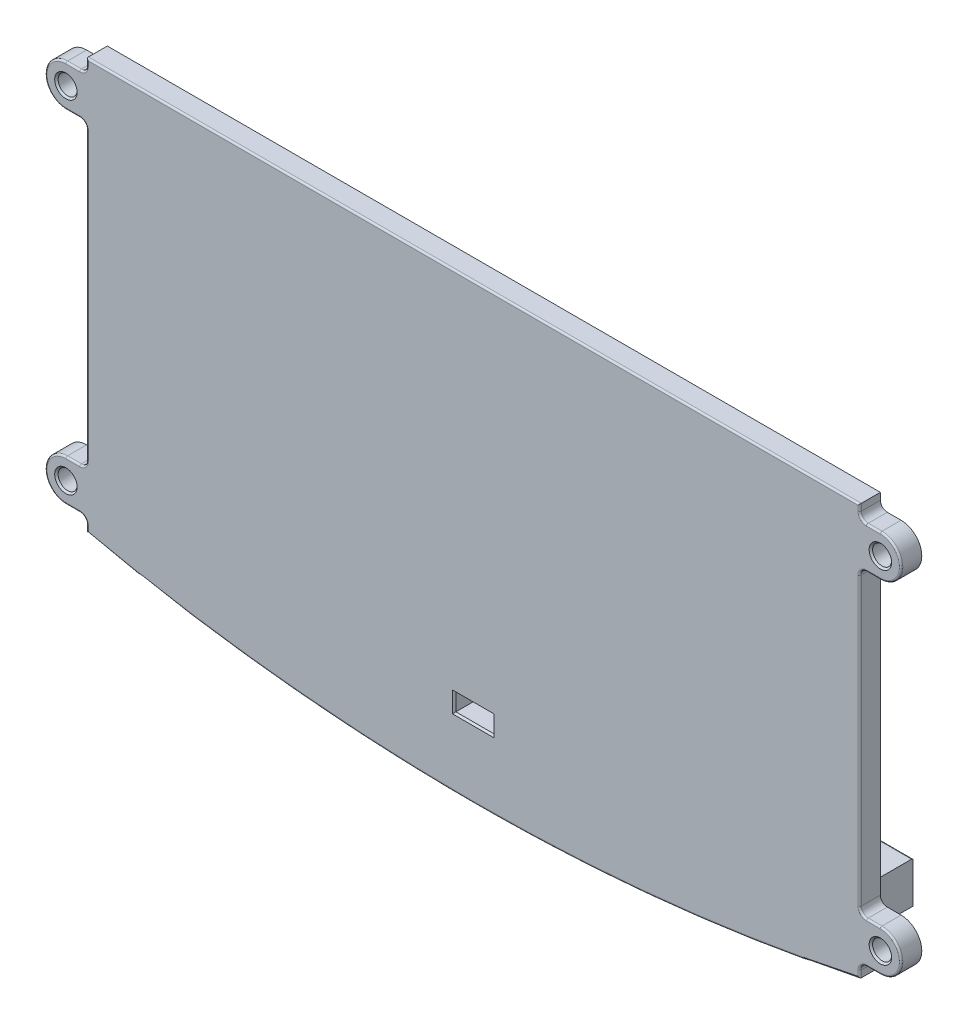
from build123d import *

# Parameters (mm, degrees)
SKETCH1_R           = 1.375
BOSS_EXTRUDE1_DEPTH = 3
SKETCH2_W           = 109
SKETCH2_H           = 3
CUT_EXTRUDE1_DEPTH  = 1.5
CHAMFER1_SIZE       = 0.25
FILLET1_R           = 0.25
SKETCH3_W           = 105.5
SKETCH3_H           = 6
BOSS_EXTRUDE2_DEPTH = 8
SKETCH4_R           = 1.75
CUT_EXTRUDE2_DEPTH  = 58.54
CUT_EXTRUDE3_DEPTH  = 2.5
SKETCH7_W           = 2
SKETCH7_H           = 15.54
SKETCH7_H_2         = 29.75
BOSS_EXTRUDE3_DEPTH = 2.5
CHAMFER2_SIZE       = 0.25
FILLET3_R           = 0.25


with BuildPart() as part:
    # Sketch1 → Boss-Extrude1 (new body)
    with BuildSketch(Plane.XY):
        with BuildLine():
            Line((-56, 3), (56, 3))
            Line((56, 3), (56, 2))
            ThreePointArc((56, 2), (56.292893219, 1.292893219), (57, 1))
            Line((57, 1), (59, 1))
            ThreePointArc((59, 1), (62, -2), (59, -5))
            Line((59, -5), (57, -5))
            ThreePointArc((57, -5), (56.292893219, -5.292893219), (56, -6))
            Line((56, -6), (56, -47.54))
            ThreePointArc((56, -47.54), (56.292893219, -48.247106781), (57, -48.54))
            Line((57, -48.54), (59, -48.54))
            ThreePointArc((59, -48.54), (62, -51.54), (59, -54.54))
            Line((59, -54.54), (57, -54.54))
            ThreePointArc((57, -54.54), (56.292893219, -54.832893219), (56, -55.54))
            Line((56, -55.54), (56, -56.54))
            ThreePointArc((56, -56.54), (0, -62.507194555), (-56, -56.54))
            Line((-56, -56.54), (-56, -55.54))
            ThreePointArc((-56, -55.54), (-56.292893219, -54.832893219), (-57, -54.54))
            Line((-57, -54.54), (-59, -54.54))
            ThreePointArc((-59, -54.54), (-62, -51.54), (-59, -48.54))
            Line((-59, -48.54), (-57, -48.54))
            ThreePointArc((-57, -48.54), (-56.292893219, -48.247106781), (-56, -47.54))
            Line((-56, -47.54), (-56, -6))
            ThreePointArc((-56, -6), (-56.292893219, -5.292893219), (-57, -5))
            Line((-57, -5), (-59, -5))
            ThreePointArc((-59, -5), (-62, -2), (-59, 1))
            Line((-59, 1), (-57, 1))
            ThreePointArc((-57, 1), (-56.292893219, 1.292893219), (-56, 2))
            Line((-56, 2), (-56, 3))
        make_face()
        with Locations((-59, -2)):
            Circle(SKETCH1_R, mode=Mode.SUBTRACT)
        with Locations((-59, -51.54)):
            Circle(SKETCH1_R, mode=Mode.SUBTRACT)
        with Locations((59, -51.54)):
            Circle(SKETCH1_R, mode=Mode.SUBTRACT)
        with Locations((59, -2)):
            Circle(SKETCH1_R, mode=Mode.SUBTRACT)
    extrude(amount=BOSS_EXTRUDE1_DEPTH)

    # Sketch2 → Cut-Extrude1 (cut)
    with BuildSketch(Plane(origin=(0, 0, 0), x_dir=(-1, 0, 0), z_dir=(0, 0, -1))):
        with Locations((0, -31.5)):
            Rectangle(SKETCH2_W, SKETCH2_H)
    extrude(amount=-CUT_EXTRUDE1_DEPTH, mode=Mode.SUBTRACT)

    # Chamfer1
    chamfer1_edges = [part.edges().sort_by_distance(p)[0] for p in [
        (-60.375, -2, 3),
        (-60.375, -51.54, 3),
        (57.625, -51.54, 3),
        (57.625, -2, 3),
    ]]
    chamfer(chamfer1_edges, length=CHAMFER1_SIZE)

    # Fillet1
    fillet1_edges = [part.edges().sort_by_distance(p)[0] for p in [
        (58, 1, 3),
        (56.292893219, 1.292893219, 3),
        (56, 2.5, 3),
        (0, 3, 3),
        (-58, 1, 3),
        (-62, -2, 3),
        (-58, -5, 3),
        (-56.292893219, -5.292893219, 3),
        (-56, -26.77, 3),
        (-56.292893219, -48.247106781, 3),
        (-58, -48.54, 3),
        (-62, -51.54, 3),
        (-58, -54.54, 3),
        (-56.292893219, -54.832893219, 3),
        (-56, 2.5, 3),
        (-56, -56.04, 3),
        (0, -62.507194555, 3),
        (56, -56.04, 3),
        (56.292893219, -54.832893219, 3),
        (58, -54.54, 3),
        (62, -51.54, 3),
        (58, -48.54, 3),
        (56.292893219, -48.247106781, 3),
        (56, -26.77, 3),
        (56.292893219, -5.292893219, 3),
        (-56.292893219, 1.292893219, 3),
        (58, -5, 3),
        (62, -2, 3),
    ]]
    fillet(fillet1_edges, radius=FILLET1_R)

    # Sketch3 → Boss-Extrude2 (add)
    with BuildSketch(Plane(origin=(0, 0, 0), x_dir=(-1, 0, 0), z_dir=(0, 0, -1))):
        with Locations((0, -51.54)):
            Rectangle(SKETCH3_W, SKETCH3_H)
    extrude(amount=BOSS_EXTRUDE2_DEPTH)

    # Sketch4 → Cut-Extrude2 (cut, through all)
    with BuildSketch(Plane.XZ.offset(54.54)):
        with Locations((0, -3.25)):
            Circle(SKETCH4_R)
    extrude(amount=-CUT_EXTRUDE2_DEPTH, mode=Mode.SUBTRACT)

    # Sketch6 → Cut-Extrude3 (cut)
    with BuildSketch(Plane(origin=(0, -52.54, 0), x_dir=(-1, 0, 0), z_dir=(0, -1, 0))):
        Polygon((2.75, 1.66228676), (2.75, -3), (-2.75, -3), (-2.75, 1.66228676), (-2.75, 4.83771324), (0, 6.425426481), (2.75, 4.83771324), align=None)
    extrude(amount=-CUT_EXTRUDE3_DEPTH, mode=Mode.SUBTRACT)

    # Sketch7 → Boss-Extrude3 (add)
    with BuildSketch(Plane(origin=(0, 0, 0), x_dir=(-1, 0, 0), z_dir=(0, 0, -1))):
        with Locations((51.75, -40.77)):
            Rectangle(SKETCH7_W, SKETCH7_H)
        with Locations((51.75, -15.125)):
            Rectangle(SKETCH7_W, SKETCH7_H_2)
        with Locations((-51.75, -15.125)):
            Rectangle(SKETCH7_W, SKETCH7_H_2)
        with Locations((-51.75, -40.77)):
            Rectangle(SKETCH7_W, SKETCH7_H)
    extrude(amount=BOSS_EXTRUDE3_DEPTH)

    # Chamfer2
    chamfer2_edges = [part.edges().sort_by_distance(p)[0] for p in [
        (-1.75, -54.54, -3.25),
        (0, -52.54, 3),
        (2.75, -51.29, 3),
        (0, -50.04, 3),
        (-2.75, -51.29, 3),
        (-1.75, -50.04, -3.25),
        (-52.75, -40.77, -2.5),
        (-51.75, -33, -2.5),
        (0, -30, 0),
        (-52.75, -15.125, -2.5),
        (-51.75, -30, -2.5),
        (51.75, -30, -2.5),
        (52.75, -15.125, -2.5),
        (0, -33, 0),
        (51.75, -33, -2.5),
        (52.75, -40.77, -2.5),
    ]]
    chamfer(chamfer2_edges, length=CHAMFER2_SIZE)

    # Fillet3
    fillet3_edges = [part.edges().sort_by_distance(p)[0] for p in [
        (-51.625, -48.54, -2.5),
        (-50.75, -48.54, -1.25),
        (51.625, -48.54, -2.5),
        (50.75, -48.54, -1.25),
        (0, -48.54, 0),
        (0, -48.54, -8),
        (50.75, -40.895, 0),
        (50.75, -15, 0),
        (50.75, -15, -2.5),
        (50.75, -40.895, -2.5),
        (-50.75, -15, -2.5),
        (-50.75, -15, 0),
        (-50.75, -40.895, 0),
        (-50.75, -40.895, -2.5),
    ]]
    fillet(fillet3_edges, radius=FILLET3_R)


solid = part.part
